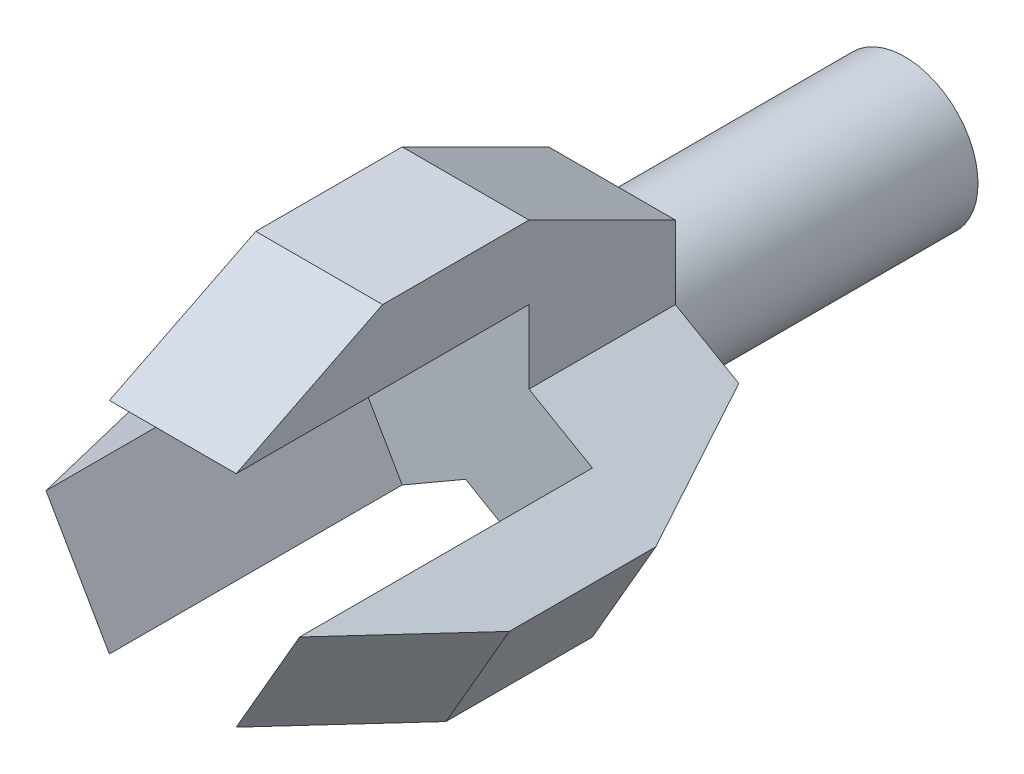
from build123d import *

# Parameters (mm, degrees)
SKETCH1_R           = 50
BOSS_EXTRUDE1_DEPTH = 200
BOSS_EXTRUDE2_DEPTH = 100
BOSS_EXTRUDE4_DEPTH = 86.60254
CIRPATTERN1_COUNT   = 3


with BuildPart() as part:
    # Sketch1 → Boss-Extrude1 (new body)
    with BuildSketch(Plane.XY):
        Circle(SKETCH1_R)
    extrude(amount=BOSS_EXTRUDE1_DEPTH)

    # Sketch2 → Boss-Extrude2 (add)
    with BuildSketch(Plane.XY.offset(200)):
        Polygon((43.301270189, 25), (43.301270189, 75), (-43.301270189, 75), (-43.301270189, 25), (0, 0), align=None)
    boss_extrude2 = extrude(amount=BOSS_EXTRUDE2_DEPTH)

    # Sketch3 → Boss-Extrude4 (add)
    with BuildSketch(Plane(origin=(-43.301270189, 0, 0), x_dir=(0, 1, 0), z_dir=(-1, 0, 0))):
        Polygon((75, -200), (75, -500), (125, -400), (125, -300), align=None)
    boss_extrude4 = extrude(amount=-BOSS_EXTRUDE4_DEPTH)

    # CirPattern1: Boss-Extrude2, Boss-Extrude4 ×3 about axis
    cirpattern1_axis = Axis((0, 0, 0), (0, 0, 1))
    for i in range(1, CIRPATTERN1_COUNT):
        add(boss_extrude2.rotate(cirpattern1_axis, i * 360 / CIRPATTERN1_COUNT))
        add(boss_extrude4.rotate(cirpattern1_axis, i * 360 / CIRPATTERN1_COUNT))


solid = part.part
